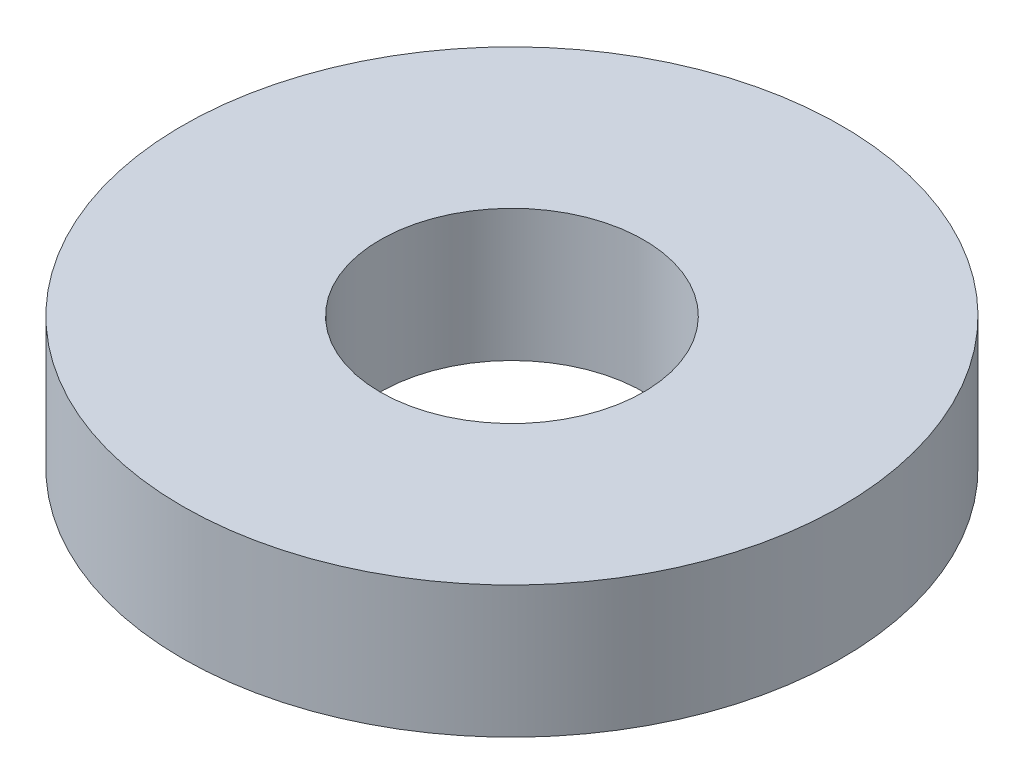
from build123d import *

# Parameters (mm, degrees)
SKETCH_1_R      = 5
SKETCH_1_R_2    = 2
EXTRUDE_1_DEPTH = 2


with BuildPart() as part:
    # 草图1 → 凸台-拉伸1 (new body)
    with BuildSketch(Plane(origin=(0, 0, 0), x_dir=(1, 0, 0), z_dir=(0, 1, 0))):
        Circle(SKETCH_1_R)
        Circle(SKETCH_1_R_2, mode=Mode.SUBTRACT)
    extrude(amount=EXTRUDE_1_DEPTH)


solid = part.part
